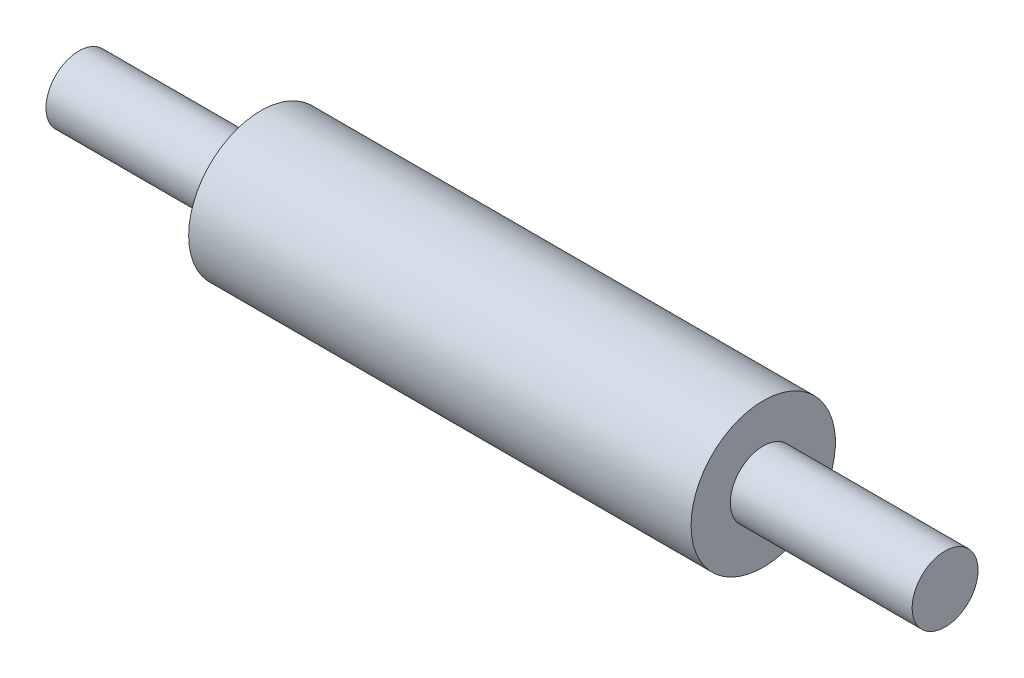
from build123d import *


with BuildPart() as part:
    # Sketch1 → Revolve1 (revolve)
    with BuildSketch(Plane.XY, mode=Mode.PRIVATE) as revolve1_sk:
        Polygon((0, 1.5875), (0, 0.725), (-4, 0.725), (-4, 0), (15.05, 0), (15.05, 0.725), (11.05, 0.725), (11.05, 1.5875), align=None)
    revolve(revolve1_sk.sketch.rotate(Axis((-19.47872402, 0, 0), (1, 0, 0)), 90), axis=Axis((-19.47872402, 0, 0), (1, 0, 0)))  # turned: the seam where the file's is


solid = part.part
